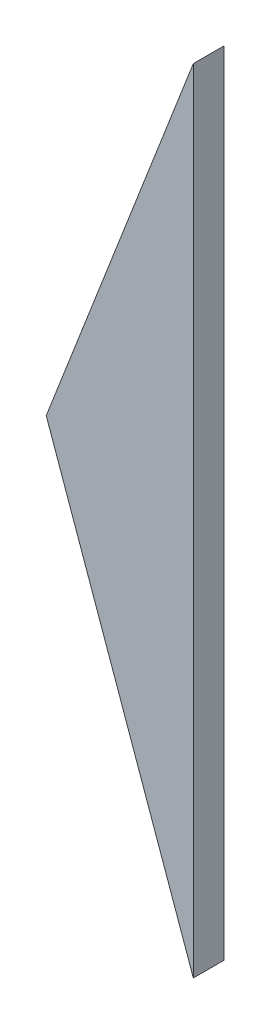
from build123d import *

# Parameters (mm, degrees)
BOSS_EXTRU_1_DEPTH = 3


with BuildPart() as part:
    # Esquisse1 → Boss.-Extru.1 (new body)
    with BuildSketch(Plane.XY):
        Polygon((-25.743066416, -66.222637248), (-11.250195051, -28.94051446), (-11.250195051, -106.952263312), align=None)
    extrude(amount=-BOSS_EXTRU_1_DEPTH)


solid = part.part
